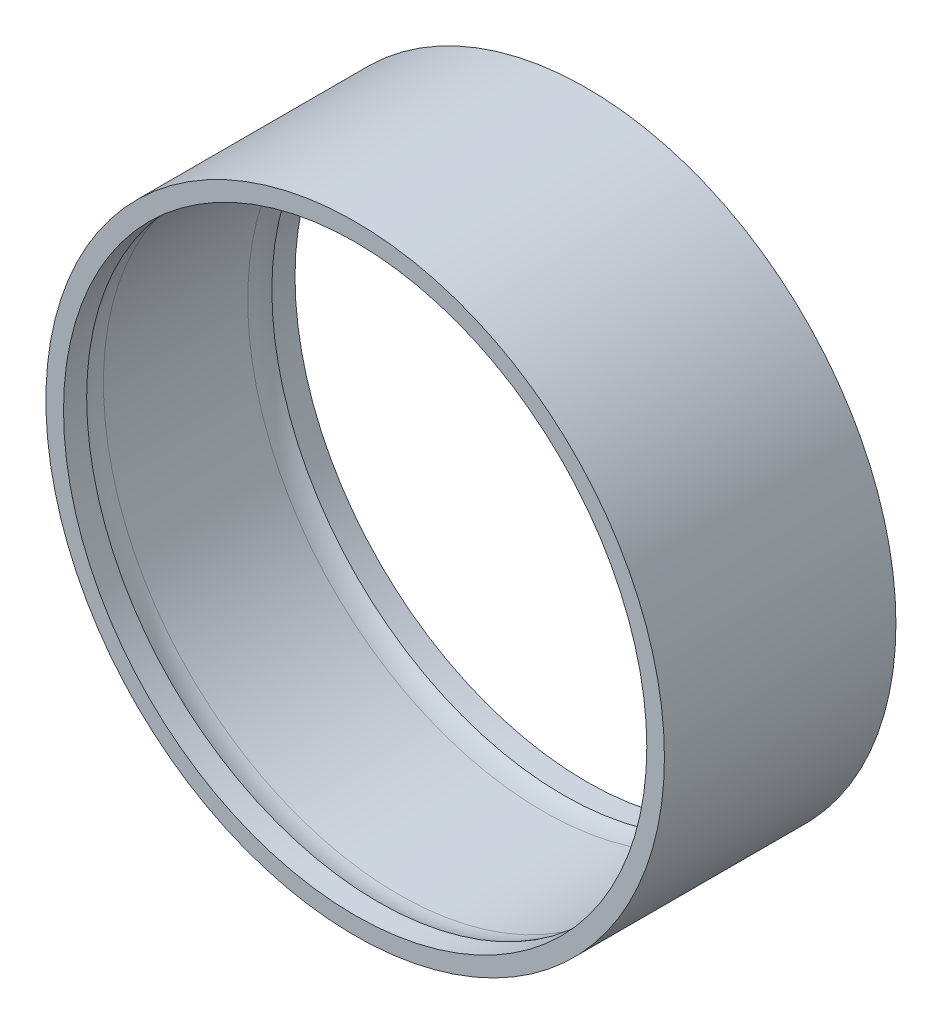
from build123d import *

# Parameters (mm, degrees)
SKETCH1_R      = 42.418
SKETCH1_R_2    = 40
EXTRUDE1_DEPTH = 15.875


with BuildPart() as part:
    # Sketch1 → Extrude1 (new body, symmetric)
    with BuildSketch(Plane.XY):
        Circle(SKETCH1_R)
        Circle(SKETCH1_R_2, mode=Mode.SUBTRACT)
    extrude(amount=EXTRUDE1_DEPTH, both=True)

    # Sketch2 → Cut-Revolve1 (revolve, cut)
    with BuildSketch(Plane(origin=(0, 0, 0), x_dir=(0, 0, -1), z_dir=(1, 0, 0))):
        with BuildLine():
            Line((-9.892740482, 40.513), (9.892740482, 40.513))
            ThreePointArc((9.892740482, 40.513), (11.31961425, 40.383696815), (12.7, 40))
            Line((12.7, 40), (15.875, 40))
            Line((15.875, 40), (15.875, 0))
            Line((15.875, 0), (-15.875, 0))
            Line((-15.875, 0), (-15.875, 40))
            Line((-15.875, 40), (-12.7, 40))
            ThreePointArc((-12.7, 40), (-11.31961425, 40.383696815), (-9.892740482, 40.513))
        make_face()
    revolve(axis=Axis((0, 0, 15.875), (0, 0, -1)), mode=Mode.SUBTRACT)


solid = part.part
